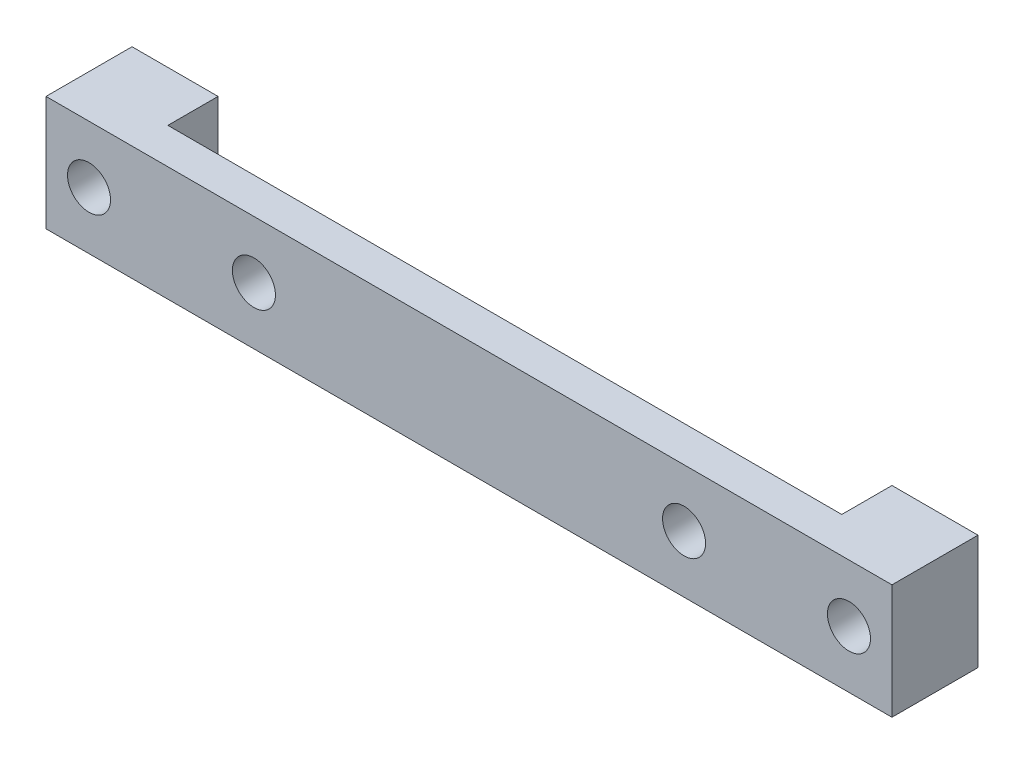
from build123d import *

# Parameters (mm, degrees)
SKETCH1_W           = 59
SKETCH1_H           = 8
SKETCH1_R           = 1.5
BOSS_EXTRUDE1_DEPTH = 6
SKETCH2_W           = 47
SKETCH2_H           = 7
CUT_EXTRUDE1_DEPTH  = 15


with BuildPart() as part:
    # Sketch1 → Boss-Extrude1 (new body)
    with BuildSketch(Plane.XY):
        Rectangle(SKETCH1_W, SKETCH1_H)
        with Locations((-26.5, 0)):
            Circle(SKETCH1_R, mode=Mode.SUBTRACT)
        with Locations((-15, 0)):
            Circle(SKETCH1_R, mode=Mode.SUBTRACT)
        with Locations((15, 0)):
            Circle(SKETCH1_R, mode=Mode.SUBTRACT)
        with Locations((26.5, 0)):
            Circle(SKETCH1_R, mode=Mode.SUBTRACT)
    extrude(amount=BOSS_EXTRUDE1_DEPTH)

    # Sketch2 → Cut-Extrude1 (cut)
    with BuildSketch(Plane(origin=(0, 4, 0), x_dir=(-1, 0, 0), z_dir=(0, 1, 0))):
        Rectangle(SKETCH2_W, SKETCH2_H)
    extrude(amount=-CUT_EXTRUDE1_DEPTH, mode=Mode.SUBTRACT)


solid = part.part
